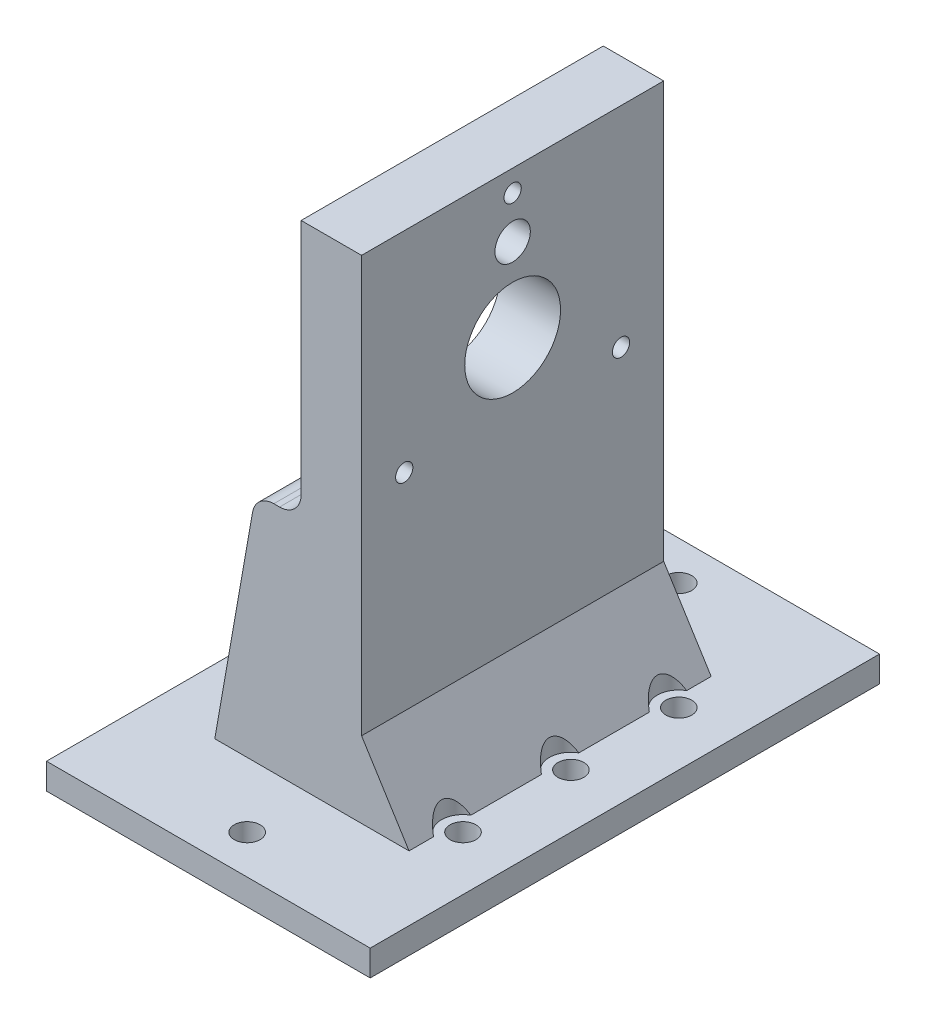
from build123d import *

# Parameters (mm, degrees)
SKETCH_1_W               = 35
SKETCH_1_H               = 70
EXTRUDE_1_DEPTH          = 6
SKETCH_1_W_2             = 26
EXTRUDE_1_2_DEPTH        = 6
SKETCH_1_3_W             = 14
SKETCH_1_3_H             = 70
EXTRUDE_2_DEPTH          = 120
EXTRUDE_4_DEPTH          = 70
EXTRUDE_7_DEPTH          = 70
SKETCH_7_R               = 3
CUT_EXTRUDE_4_DEPTH      = 121
SKETCH_8_R               = 5
CUT_EXTRUDE_5_DEPTH      = 115
SKETCH_3_R               = 11.1
SKETCH_3_R_2             = 4.1
SKETCH_3_R_3             = 2
CUT_EXTRUDE_8_DEPTH      = 36
CUT_EXTRUDE_8_DEPTH_BACK = 41
SKETCH_10_W              = 75
SKETCH_10_H              = 24
EXTRUDE_8_DEPTH          = 6
SKETCH_11_R              = 3
CUT_EXTRUDE_9_DEPTH      = 6
SKETCH_12_W              = 56.46589335
SKETCH_12_H              = 70
CUT_EXTRUDE_10_DEPTH     = 60
FILLET_1_R               = 5


with BuildPart() as part:
    # 草图1 → 凸台-拉伸1 (new body)
    with BuildSketch(Plane(origin=(0, 0, 0), x_dir=(1, 0, 0), z_dir=(0, 1, 0))):
        with Locations((17.5, -35)):
            Rectangle(SKETCH_1_W, SKETCH_1_H)
    extrude(amount=EXTRUDE_1_DEPTH)



with BuildPart() as body_2:
    # 草图1 → Extrude 1 2 (new body)
    with BuildSketch(Plane(origin=(0, 0, 0), x_dir=(1, 0, 0), z_dir=(0, 1, 0))):
        with Locations((62, -35)):
            Rectangle(SKETCH_1_W_2, SKETCH_1_H)
    extrude(amount=EXTRUDE_1_2_DEPTH)


with BuildPart() as part_1:
    add(part.part)

    add(body_2.part)  # 凸台-拉伸2 merges body 2
    # 草图1<3> → 凸台-拉伸2 (add)
    with BuildSketch(Plane(origin=(0, 0, 0), x_dir=(1, 0, 0), z_dir=(0, 1, 0))):
        with Locations((42, -35)):
            Rectangle(SKETCH_1_3_W, SKETCH_1_3_H)
    extrude(amount=EXTRUDE_2_DEPTH)

    # 草图4 → 凸台-拉伸4 (add, through all)
    with BuildSketch(Plane(origin=(0, 0, 0), x_dir=(-1, 0, 0), z_dir=(0, 0, -1))):
        Polygon((-35, 6), (-15, 6), (-35, 38), align=None)
        Polygon((-60, 6), (-40, 38), (-40, 6), align=None)
    extrude(amount=-EXTRUDE_4_DEPTH)

    # 草图9 → 凸台-拉伸7 (add, through all)
    with BuildSketch(Plane(origin=(0, 0, 0), x_dir=(-1, 0, 0), z_dir=(0, 0, -1))):
        Polygon((-35, 120), (-15, 6), (-35, 0), align=None)
    extrude(amount=-EXTRUDE_7_DEPTH)

    # 草图7 → 切除-拉伸4 (cut, through all)
    with BuildSketch(Plane.XZ):
        with Locations((12.5, 35)):
            Circle(SKETCH_7_R)
        with Locations((12.5, 60)):
            Circle(SKETCH_7_R)
        with Locations((12.5, 10)):
            Circle(SKETCH_7_R)
        with BuildLine():
            ThreePointArc((65.5, 10), (64.621320344, 12.121320344), (62.5, 13))
            Line((62.5, 13), (62.5, 7))
            ThreePointArc((62.5, 7), (64.621320344, 7.878679656), (65.5, 10))
        make_face()
        with BuildLine():
            Line((62.5, 7), (62.5, 13))
            ThreePointArc((62.5, 13), (59.5, 10), (62.5, 7))
        make_face()
        with BuildLine():
            ThreePointArc((65.5, 35), (64.621320344, 37.121320344), (62.5, 38))
            Line((62.5, 38), (62.5, 32))
            ThreePointArc((62.5, 32), (64.621320344, 32.878679656), (65.5, 35))
        make_face()
        with BuildLine():
            Line((62.5, 32), (62.5, 38))
            ThreePointArc((62.5, 38), (59.5, 35), (62.5, 32))
        make_face()
        with BuildLine():
            ThreePointArc((65.5, 60), (64.621320344, 62.121320344), (62.5, 63))
            Line((62.5, 63), (62.5, 57))
            ThreePointArc((62.5, 57), (64.621320344, 57.878679656), (65.5, 60))
        make_face()
        with BuildLine():
            Line((62.5, 57), (62.5, 63))
            ThreePointArc((62.5, 63), (59.5, 60), (62.5, 57))
        make_face()
    extrude(amount=-CUT_EXTRUDE_4_DEPTH, mode=Mode.SUBTRACT)

    # 草图8 → 切除-拉伸5 (cut)
    with BuildSketch(Plane(origin=(0, 6, 0), x_dir=(1, 0, 0), z_dir=(0, 1, 0))):
        with Locations((12.5, -10)):
            Circle(SKETCH_8_R)
        with Locations((62.5, -10)):
            Circle(SKETCH_8_R)
        with Locations((62.5, -35)):
            Circle(SKETCH_8_R)
        with Locations((62.5, -60)):
            Circle(SKETCH_8_R)
        with Locations((12.5, -35)):
            Circle(SKETCH_8_R)
        with Locations((12.5, -60)):
            Circle(SKETCH_8_R)
    extrude(amount=CUT_EXTRUDE_5_DEPTH, mode=Mode.SUBTRACT)

    # 草图3 → 切除-拉伸8 (cut, two sides)
    with BuildSketch(Plane.ZY.offset(-35)) as cut_extrude_8_sk:
        with Locations((35, 86)):
            Circle(SKETCH_3_R)
        with Locations((35, 105.25)):
            Circle(SKETCH_3_R_2)
        with Locations((35, 115)):
            Circle(SKETCH_3_R_3)
        with Locations((60.11473671, 71.5)):
            Circle(SKETCH_3_R_3)
        with Locations((9.88526329, 71.5)):
            Circle(SKETCH_3_R_3)
    extrude(amount=CUT_EXTRUDE_8_DEPTH, mode=Mode.SUBTRACT)
    extrude(cut_extrude_8_sk.sketch, amount=-CUT_EXTRUDE_8_DEPTH_BACK, mode=Mode.SUBTRACT)

    # 草图10 → 凸台-拉伸8 (add)
    with BuildSketch(Plane.XZ):
        with Locations((37.5, 82)):
            Rectangle(SKETCH_10_W, SKETCH_10_H)
    extrude_8 = extrude(amount=-EXTRUDE_8_DEPTH)

    # 草图11 → 切除-拉伸9 (cut)
    with BuildSketch(Plane(origin=(0, 6, 0), x_dir=(1, 0, 0), z_dir=(0, 1, 0))):
        with Locations((37.5, -85)):
            Circle(SKETCH_11_R)
    cut_extrude_9 = extrude(amount=-CUT_EXTRUDE_9_DEPTH, mode=Mode.SUBTRACT)

    # 镜向1: 凸台-拉伸8, 切除-拉伸9 across plane
    add(extrude_8.mirror(Plane.XY.offset(35)))
    add(cut_extrude_9.mirror(Plane.XY.offset(35)), mode=Mode.SUBTRACT)

    # 草图12 → 切除-拉伸10 (cut)
    with BuildSketch(Plane(origin=(0, 120, 0), x_dir=(1, 0, 0), z_dir=(0, 1, 0))):
        with Locations((6.767053325, -35)):
            Rectangle(SKETCH_12_W, SKETCH_12_H)
    extrude(amount=-CUT_EXTRUDE_10_DEPTH, mode=Mode.SUBTRACT)

    # 圆角1
    fillet_1_edges = [part_1.edges().sort_by_distance(p)[0] for p in [
        (24.473684211, 60, 35),
        (35, 60, 35),
    ]]
    fillet(fillet_1_edges, radius=FILLET_1_R)


solid = part_1.part
